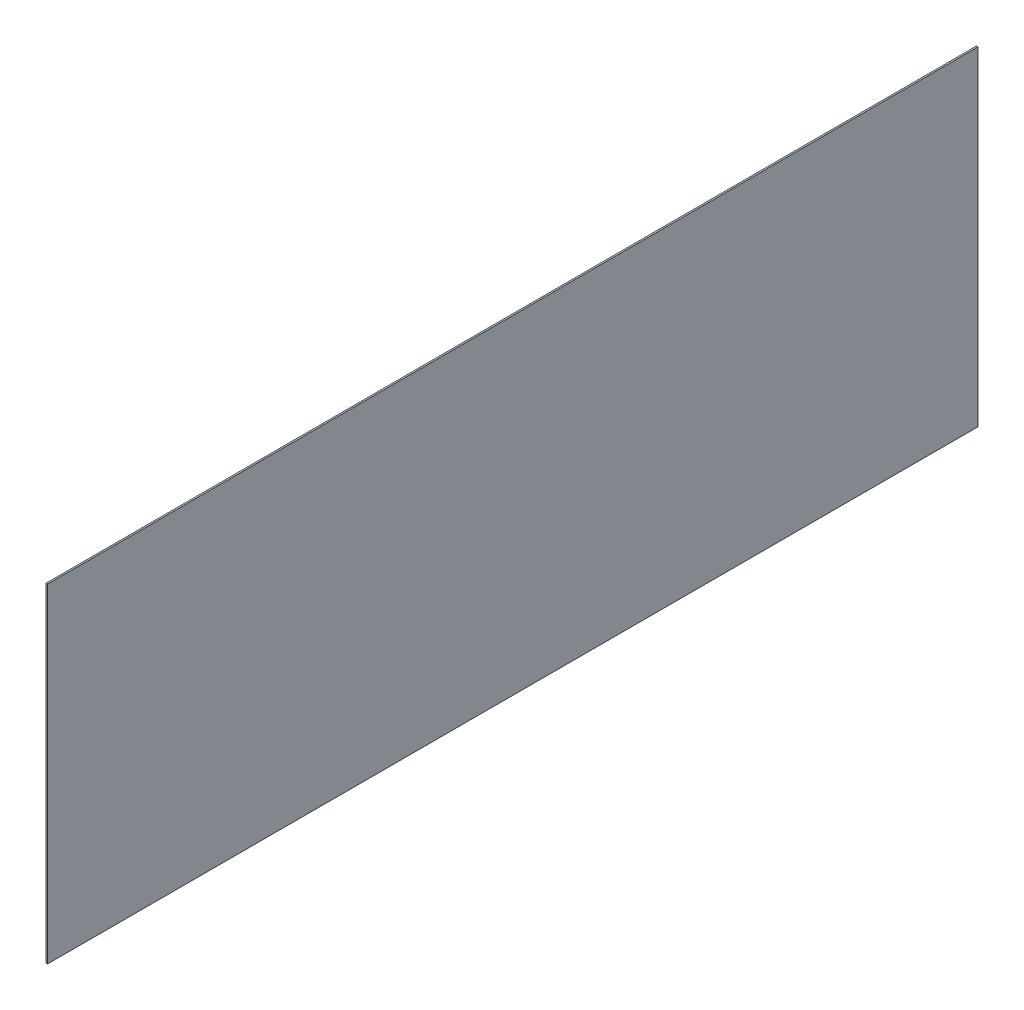
from build123d import *

# Parameters (mm, degrees)
SKETCH_1_W      = 6000
SKETCH_1_H      = 2121.32
EXTRUDE_1_DEPTH = 10


with BuildPart() as part:
    # 草图1 → 凸台-拉伸1 (new body)
    with BuildSketch(Plane(origin=(0, 0, 0), x_dir=(0, 0, -1), z_dir=(1, 0, 0))):
        with Locations((3000, 1060.66)):
            Rectangle(SKETCH_1_W, SKETCH_1_H)
    extrude(amount=EXTRUDE_1_DEPTH)


solid = part.part
